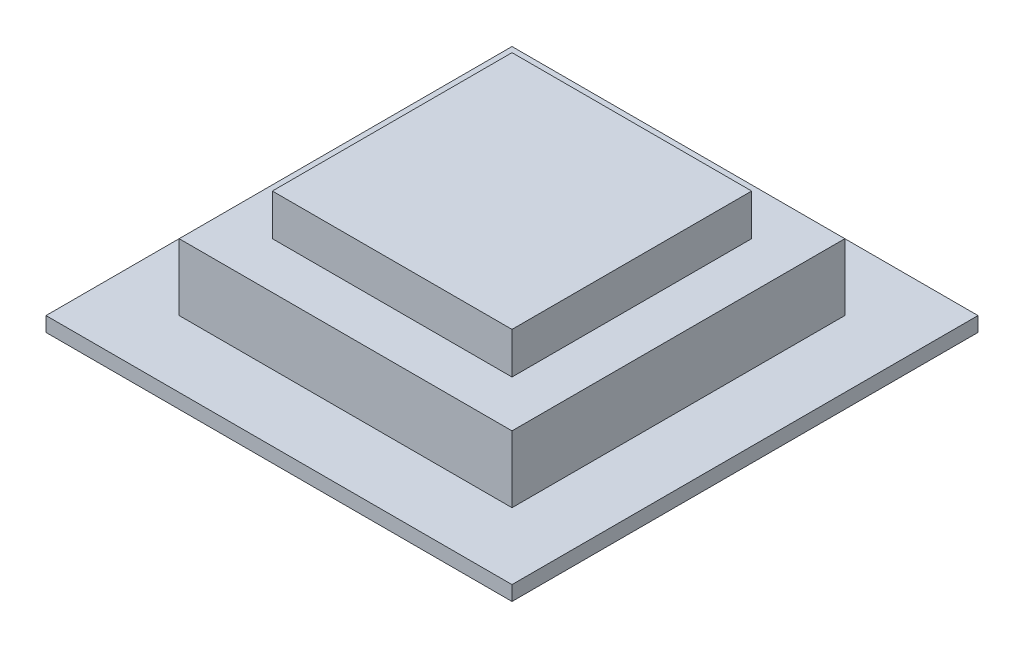
from build123d import *

# Parameters (mm, degrees)
SKETCH1_W           = 35
SKETCH1_H           = 35
BOSS_EXTRUDE1_DEPTH = 1.1
SKETCH2_W           = 25
SKETCH2_H           = 25
BOSS_EXTRUDE2_DEPTH = 5
SKETCH3_W           = 18
SKETCH3_H           = 18
BOSS_EXTRUDE6_DEPTH = 3.1


with BuildPart() as part:
    # Sketch1 → Boss-Extrude1 (new body)
    with BuildSketch(Plane(origin=(0, 0, 0), x_dir=(1, 0, 0), z_dir=(0, 1, 0))):
        Rectangle(SKETCH1_W, SKETCH1_H)
    extrude(amount=BOSS_EXTRUDE1_DEPTH)

    # Sketch2 → Boss-Extrude2 (add)
    with BuildSketch(Plane(origin=(0, 1.1, 0), x_dir=(1, 0, 0), z_dir=(0, 1, 0))):
        Rectangle(SKETCH2_W, SKETCH2_H)
    extrude(amount=BOSS_EXTRUDE2_DEPTH)

    # Sketch3 → Boss-Extrude6 (add)
    with BuildSketch(Plane(origin=(0, 6.1, 0), x_dir=(1, 0, 0), z_dir=(0, 1, 0))):
        Rectangle(SKETCH3_W, SKETCH3_H)
    extrude(amount=BOSS_EXTRUDE6_DEPTH)


solid = part.part
